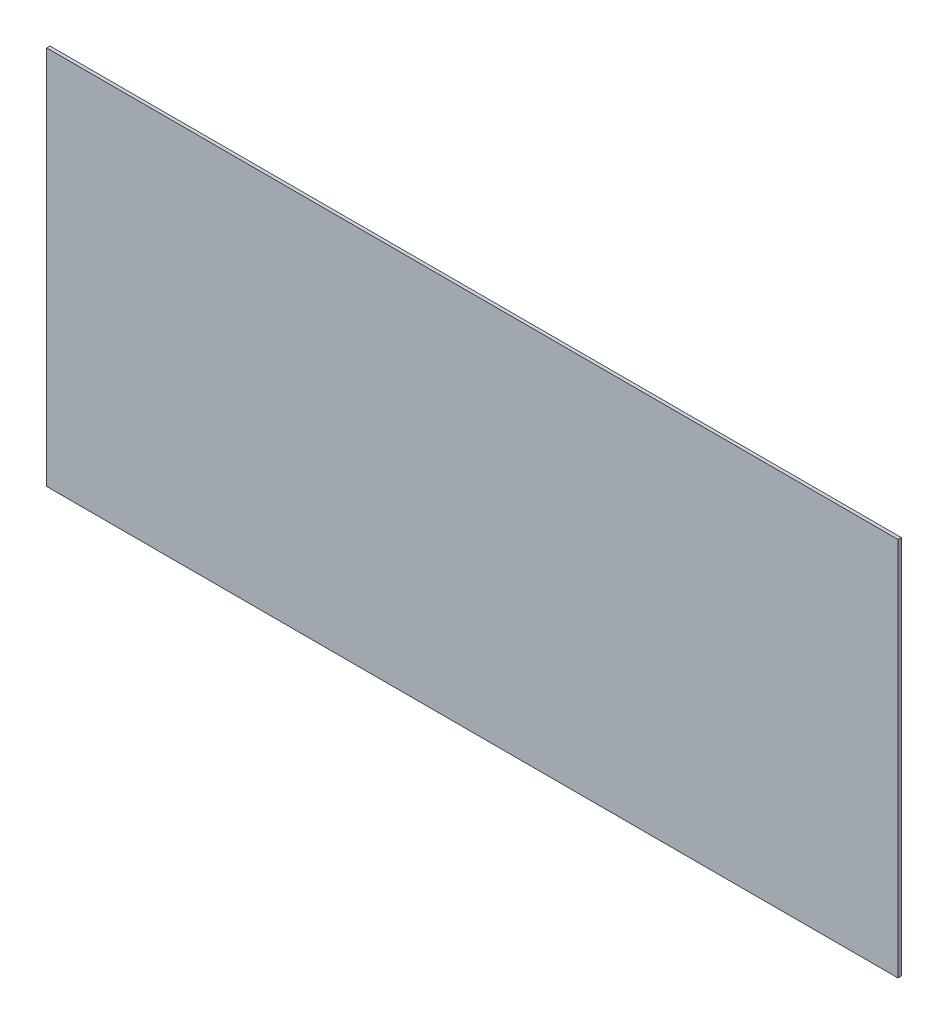
from build123d import *

# Parameters (mm, degrees)
ESQUISSE1_W        = 26
ESQUISSE1_H        = 11.6
BOSS_EXTRU_1_DEPTH = 0.1


with BuildPart() as part:
    # Esquisse1 → Boss.-Extru.1 (new body)
    with BuildSketch(Plane.XY):
        Rectangle(ESQUISSE1_W, ESQUISSE1_H)
    extrude(amount=BOSS_EXTRU_1_DEPTH)


solid = part.part
